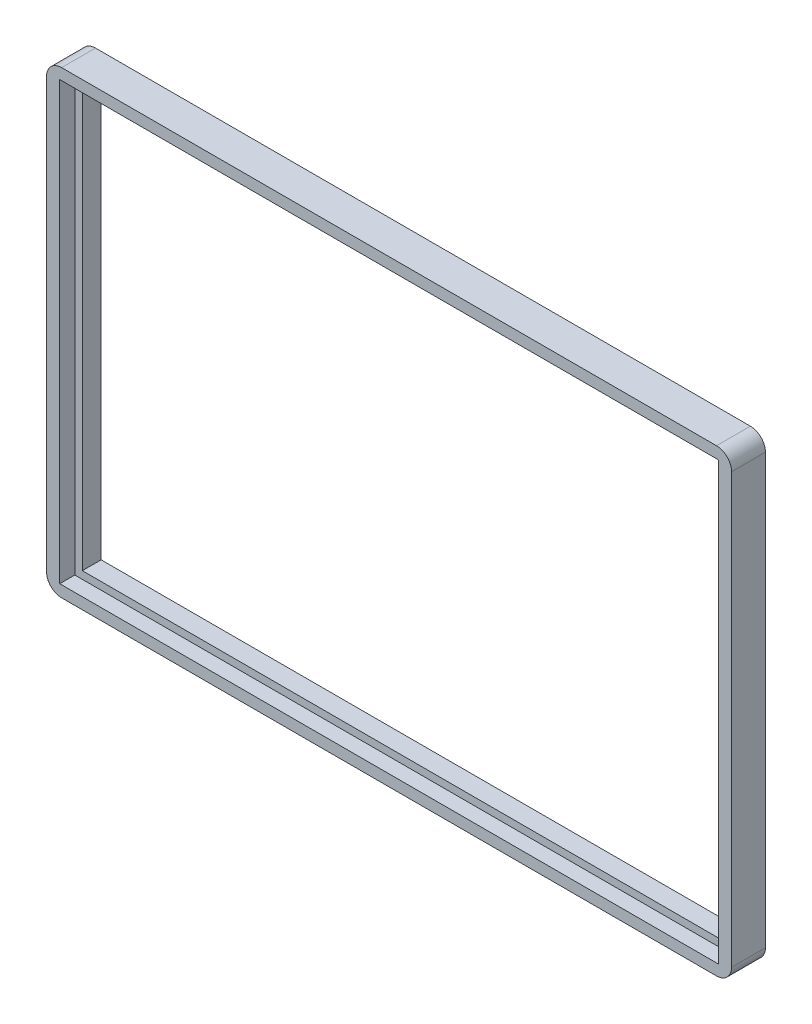
from build123d import *

# Parameters (mm, degrees)
SKETCH1_W           = 91
SKETCH1_H           = 61
BOSS_EXTRUDE1_DEPTH = 4.5
SKETCH2_W           = 87.5
SKETCH2_H           = 58
CUT_EXTRUDE1_DEPTH  = 2
SKETCH3_W           = 85.5
SKETCH3_H           = 56
CUT_EXTRUDE2_DEPTH  = 3.5
FILLET1_R           = 2


with BuildPart() as part:
    # Sketch1 → Boss-Extrude1 (new body)
    with BuildSketch(Plane.XY):
        Rectangle(SKETCH1_W, SKETCH1_H)
    extrude(amount=BOSS_EXTRUDE1_DEPTH)

    # Sketch2 → Cut-Extrude1 (cut)
    with BuildSketch(Plane.XY.offset(4.5)):
        Rectangle(SKETCH2_W, SKETCH2_H)
    extrude(amount=-CUT_EXTRUDE1_DEPTH, mode=Mode.SUBTRACT)

    # Sketch3 → Cut-Extrude2 (cut, through all)
    with BuildSketch(Plane.XY.offset(2.5)):
        Rectangle(SKETCH3_W, SKETCH3_H)
    extrude(amount=-CUT_EXTRUDE2_DEPTH, mode=Mode.SUBTRACT)

    # Fillet1
    fillet1_edges = [part.edges().sort_by_distance(p)[0] for p in [
        (45.5, -30.5, 2.25),
        (-45.5, -30.5, 2.25),
        (-45.5, 30.5, 2.25),
        (45.5, 30.5, 2.25),
    ]]
    fillet(fillet1_edges, radius=FILLET1_R)


solid = part.part
